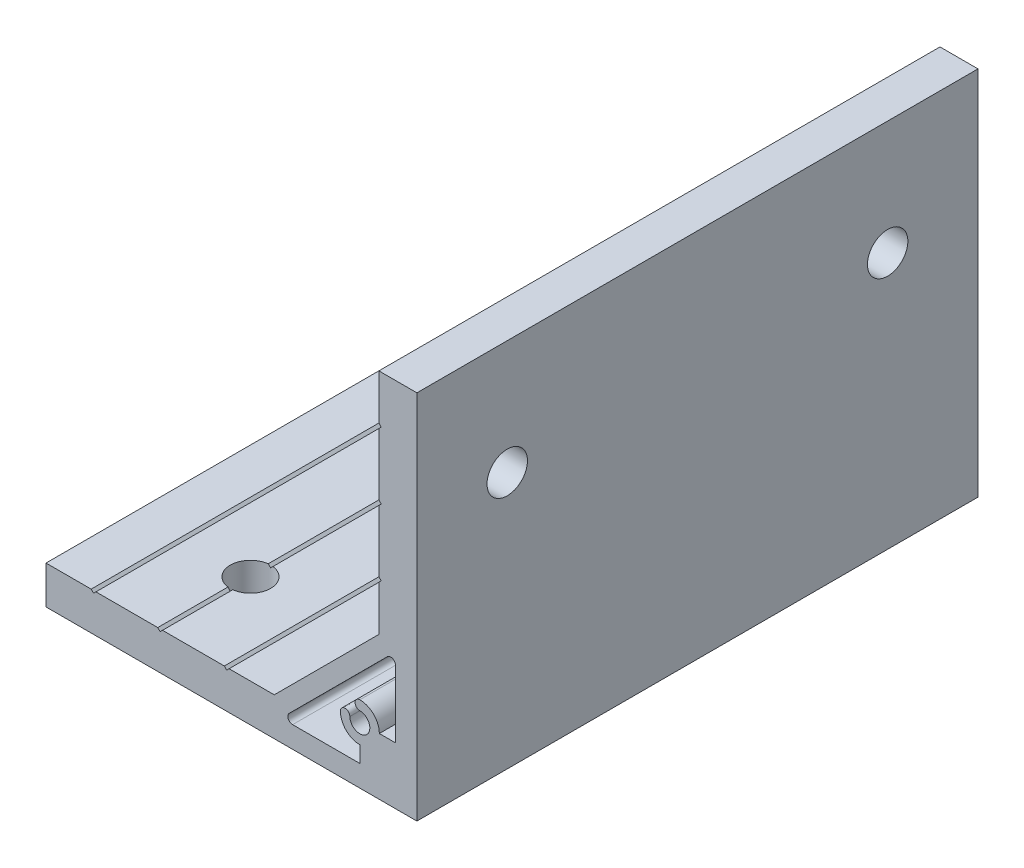
from build123d import *

# Parameters (mm, degrees)
EXTRUDE_1_DEPTH     = 59
SKETCH_2_R          = 4.25
CUT_EXTRUDE_1_DEPTH = 9
SKETCH_3_R          = 4.25
CUT_EXTRUDE_2_DEPTH = 9


with BuildPart() as part:
    # Эскиз1 → Бобышка-Вытянуть1 (new body, symmetric)
    with BuildSketch(Plane.XY):
        Polygon((-78, 0), (0, 0), (0, 78), (-8, 78), (-8, 68.5), (-7.5, 68), (-8, 67.5), (-8, 54.5), (-7.5, 54), (-8, 53.5), (-8, 40.5), (-7.5, 40), (-8, 39.5), (-8, 30), (-30, 8), (-39.5, 8), (-40, 7.5), (-40.5, 8), (-53.5, 8), (-54, 7.5), (-54.5, 8), (-67.5, 8), (-68, 7.5), (-68.5, 8), (-78, 8), align=None)
        with BuildLine():
            Line((-4.5, 12), (-4.5, 26.136038969))
            ThreePointArc((-4.5, 26.136038969), (-5.117316568, 27.059918502), (-6.207106781, 26.843145751))
            Line((-6.207106781, 26.843145751), (-26.843145751, 6.207106781))
            ThreePointArc((-26.843145751, 6.207106781), (-27.059918502, 5.117316568), (-26.136038969, 4.5))
            Line((-26.136038969, 4.5), (-12, 4.5))
            Line((-12, 4.5), (-12, 7.9))
            ThreePointArc((-12, 7.9), (-14.899137803, 9.100862197), (-16.1, 12))
            ThreePointArc((-16.1, 12), (-15.1, 13), (-14.1, 12))
            ThreePointArc((-14.1, 12), (-10.51507576, 10.51507576), (-12, 14.1))
            ThreePointArc((-12, 14.1), (-13, 15.1), (-12, 16.1))
            ThreePointArc((-12, 16.1), (-9.100862197, 14.899137803), (-7.9, 12))
            Line((-7.9, 12), (-4.5, 12))
        make_face(mode=Mode.SUBTRACT)
    extrude(amount=EXTRUDE_1_DEPTH, both=True)

    # Эскиз2 → Вырез-Вытянуть1 (cut, through all)
    with BuildSketch(Plane.ZY.offset(8)):
        with Locations(Location((-40, 54, 0), (0, 0, 270))):  # turned: the seam where the file's is
            Circle(SKETCH_2_R)
        with Locations(Location((40, 54, 0), (0, 0, 270))):  # turned: the seam where the file's is
            Circle(SKETCH_2_R)
    extrude(amount=-CUT_EXTRUDE_1_DEPTH, mode=Mode.SUBTRACT)

    # Эскиз3 → Вырез-Вытянуть2 (cut, through all)
    with BuildSketch(Plane(origin=(0, 8, 0), x_dir=(1, 0, 0), z_dir=(0, 1, 0))):
        with Locations(Location((-54, -40, 0), (0, 0, 180))):  # turned: the seam where the file's is
            Circle(SKETCH_3_R)
        with Locations(Location((-54, 40, 0), (0, 0, 180))):  # turned: the seam where the file's is
            Circle(SKETCH_3_R)
    extrude(amount=-CUT_EXTRUDE_2_DEPTH, mode=Mode.SUBTRACT)


solid = part.part
